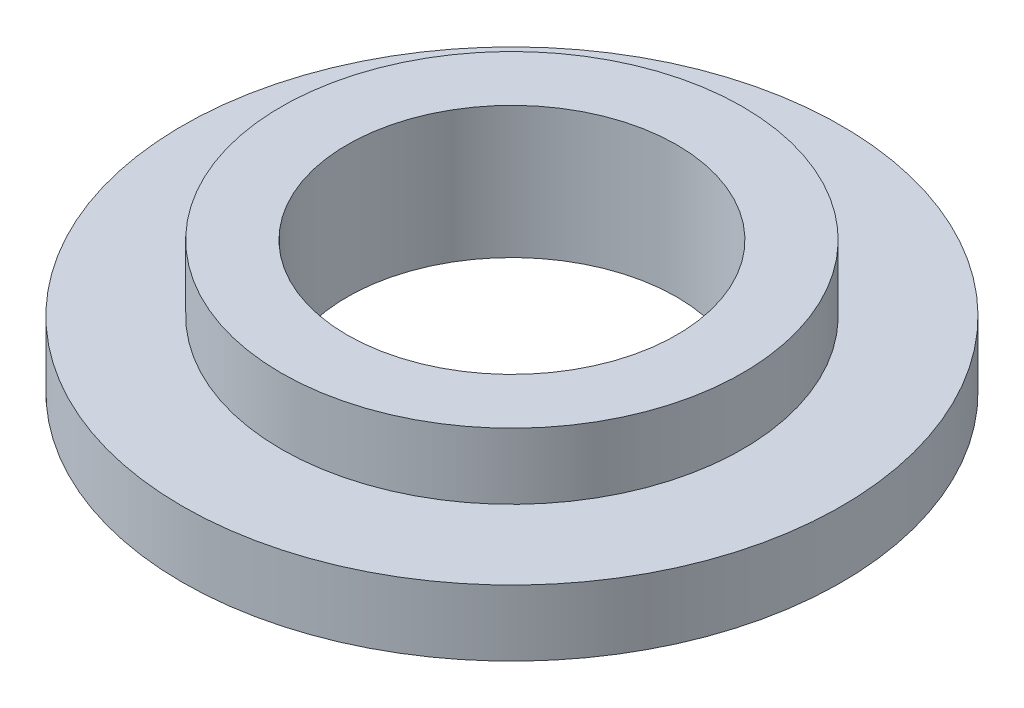
from build123d import *


with BuildPart() as part:
    # Эскиз1 → Повернуть1 (revolve)
    with BuildSketch(Plane(origin=(0, 0, 0), x_dir=(0, 0, -1), z_dir=(1, 0, 0))):
        Polygon((25, 0), (50, 0), (50, 10), (35, 10), (35, 20), (25, 20), align=None)
    revolve(axis=Axis((0, 30.784053945, 0), (0, -1, 0)))


solid = part.part
